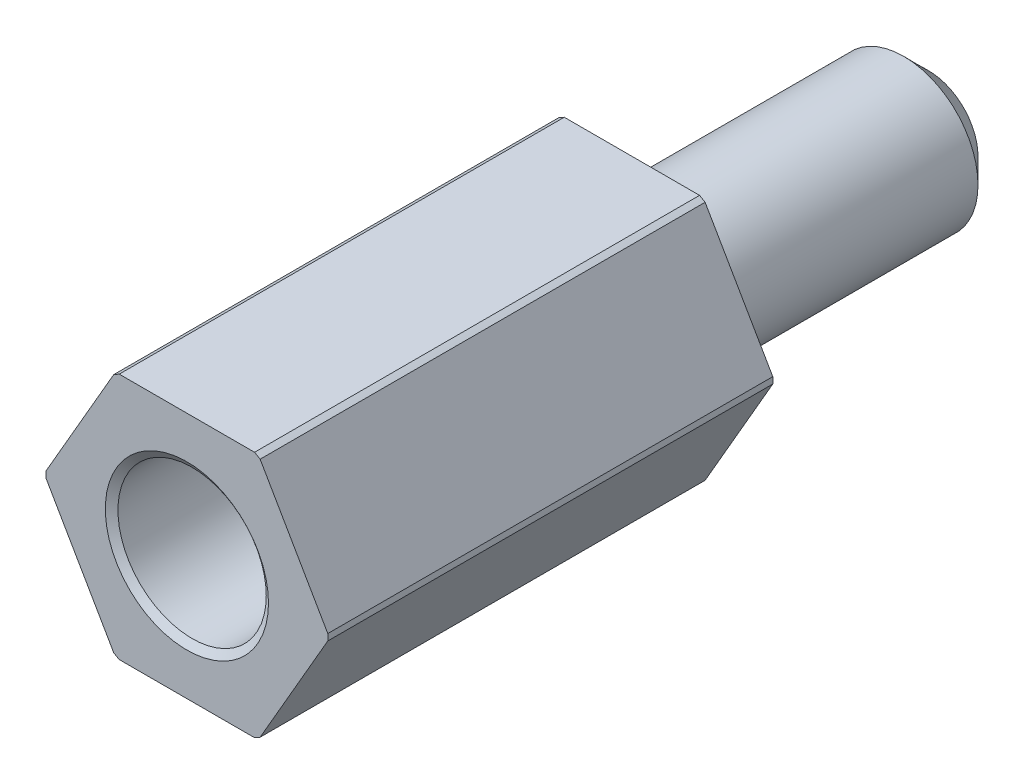
from build123d import *

# Parameters (mm, degrees)
EXTRUDE_1_DEPTH = 15
CHAMFER_1_SIZE  = 0.5


with BuildPart() as part:
    # Эскиз1 → Бобышка-Вытянуть1 (new body)
    with BuildSketch(Plane.XY):
        Polygon((2.886751346, 0), (1.443375673, 2.5), (-1.443375673, 2.5), (-2.886751346, 0), (-1.443375673, -2.5), (1.443375673, -2.5), align=None)
    extrude(amount=EXTRUDE_1_DEPTH)

    # Эскиз3 → Вырез-Повернуть1 (revolve, cut)
    with BuildSketch(Plane(origin=(0, 0, 0), x_dir=(1, 0, 0), z_dir=(0, 1, 0))):
        Polygon((-2.886751346, 0), (-1.5, 0), (-1.5, -6), (-2.85, -6), (-2.85, -15), (-2.886751346, -15), align=None)
    revolve(axis=Axis((0, 0, 0), (0, 0, 1)), mode=Mode.SUBTRACT)

    # Фаска1
    chamfer_1_edges = [part.edges().sort_by_distance(p)[0] for p in [
        (1.5, 0, 0),
    ]]
    chamfer(chamfer_1_edges, length=CHAMFER_1_SIZE)

    # Эскиз4 → Отверстие обработанное метчиком M31 (revolve, cut)
    with BuildSketch(Plane(origin=(0, 0, 15), x_dir=(0, -1, 0), z_dir=(1, 0, 0))):
        Polygon((0, 0), (0, 7.751075774), (1.25, 7), (1.25, 5), (1.5, 5), (1.5, 0.105031131), (1.65, 0), align=None)
    revolve(axis=Axis((0, 0, 21.35), (0, 0, -1)), mode=Mode.SUBTRACT)


solid = part.part
